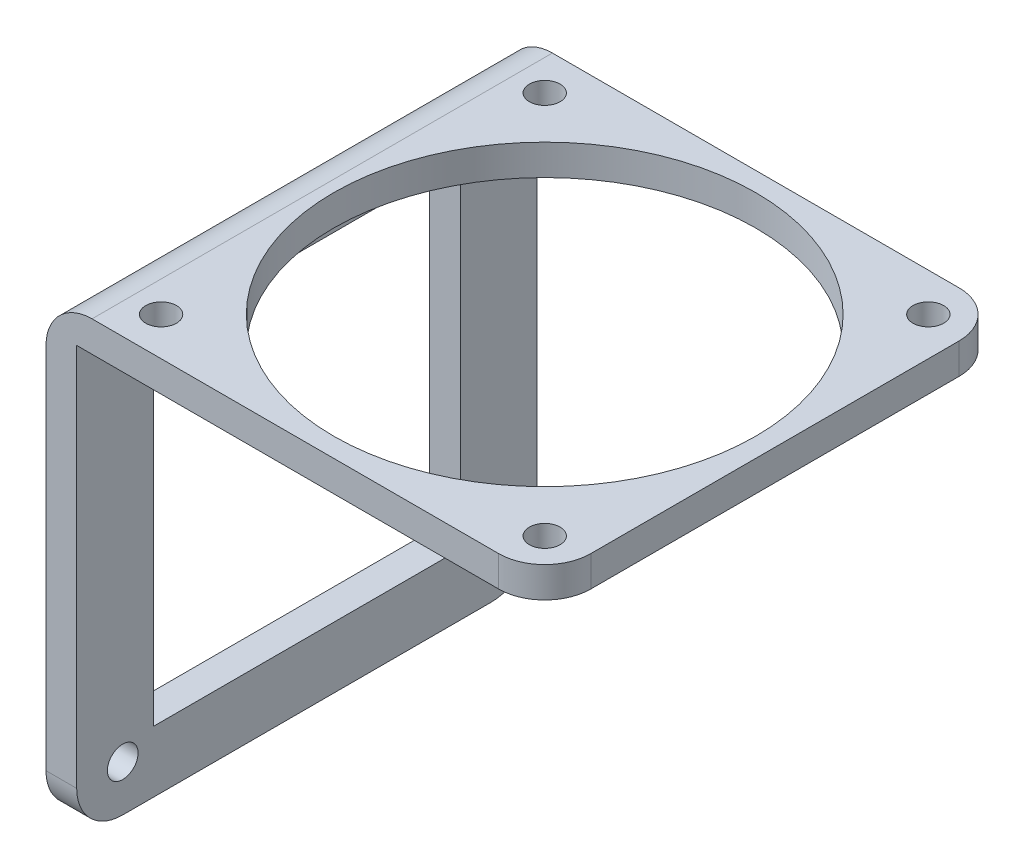
from build123d import *

# Parameters (mm, degrees)
RESSALTO_EXTRUS_O1_DEPTH = 60
ESBO_O2_W                = 40
ESBO_O2_H                = 44
CORTE_EXTRUS_O1_DEPTH    = 66
CORTE_EXTRUS_O3_REACH    = 62
ESBO_O4_R                = 2
ESBO_O5_R                = 27.5
CORTE_EXTRUS_O4_DEPTH    = 5
ESBO_O6_R                = 2
CORTE_EXTRUS_O5_DEPTH    = 10
FILETE2_R                = 6


with BuildPart() as part:
    # Esboço1 → Ressalto-extrusão1 (new body)
    with BuildSketch(Plane.XY):
        Polygon((0, 0), (4, 0), (4, 56), (65, 56), (65, 60), (0, 60), align=None)
    extrude(amount=RESSALTO_EXTRUS_O1_DEPTH)

    # Esboço2 → Corte-extrusão1 (cut, through all)
    with BuildSketch(Plane.ZY):
        with Locations((30, 30)):
            Rectangle(ESBO_O2_W, ESBO_O2_H)
    extrude(amount=-CORTE_EXTRUS_O1_DEPTH, mode=Mode.SUBTRACT)

    # Esboço4 → Corte-extrusão3 (cut, up to next)
    with BuildSketch(Plane.ZX.offset(60), mode=Mode.PRIVATE) as corte_extrus_o3_sk1:
        with Locations((5, 60)):
            Circle(ESBO_O4_R)
    corte_extrus_o3_tool1 = extrude(corte_extrus_o3_sk1.sketch, amount=-CORTE_EXTRUS_O3_REACH, mode=Mode.PRIVATE) & part.part
    add(corte_extrus_o3_tool1.solids().sort_by_distance((60, 60, 5))[0], mode=Mode.SUBTRACT)
    # Esboço4 → Corte-extrusão3 (cut, up to next)
    with BuildSketch(Plane.ZX.offset(60), mode=Mode.PRIVATE) as corte_extrus_o3_sk2:
        with Locations((55, 60)):
            Circle(ESBO_O4_R)
    corte_extrus_o3_tool2 = extrude(corte_extrus_o3_sk2.sketch, amount=-CORTE_EXTRUS_O3_REACH, mode=Mode.PRIVATE) & part.part
    add(corte_extrus_o3_tool2.solids().sort_by_distance((60, 60, 55))[0], mode=Mode.SUBTRACT)
    # Esboço4 → Corte-extrusão3 (cut, up to next)
    with BuildSketch(Plane.ZX.offset(60), mode=Mode.PRIVATE) as corte_extrus_o3_sk3:
        with Locations((5, 10)):
            Circle(ESBO_O4_R)
    corte_extrus_o3_tool3 = extrude(corte_extrus_o3_sk3.sketch, amount=-CORTE_EXTRUS_O3_REACH, mode=Mode.PRIVATE) & part.part
    add(corte_extrus_o3_tool3.solids().sort_by_distance((10, 60, 5))[0], mode=Mode.SUBTRACT)
    # Esboço4 → Corte-extrusão3 (cut, up to next)
    with BuildSketch(Plane.ZX.offset(60), mode=Mode.PRIVATE) as corte_extrus_o3_sk4:
        with Locations((55, 10)):
            Circle(ESBO_O4_R)
    corte_extrus_o3_tool4 = extrude(corte_extrus_o3_sk4.sketch, amount=-CORTE_EXTRUS_O3_REACH, mode=Mode.PRIVATE) & part.part
    add(corte_extrus_o3_tool4.solids().sort_by_distance((10, 60, 55))[0], mode=Mode.SUBTRACT)

    # Esboço5 → Corte-extrusão4 (cut, through all)
    with BuildSketch(Plane(origin=(0, 56, 0), x_dir=(0, 0, -1), z_dir=(0, -1, 0))):
        with Locations((-30, 35)):
            Circle(ESBO_O5_R)
    extrude(amount=-CORTE_EXTRUS_O4_DEPTH, mode=Mode.SUBTRACT)

    # Esboço6 → Corte-extrusão5 (cut)
    with BuildSketch(Plane.ZY):
        with Locations((6, 6)):
            Circle(ESBO_O6_R)
        with Locations((54, 6)):
            Circle(ESBO_O6_R)
    extrude(amount=-CORTE_EXTRUS_O5_DEPTH, mode=Mode.SUBTRACT)

    # Filete2
    filete2_edges = [part.edges().sort_by_distance(p)[0] for p in [
        (0, 60, 30),
        (65, 58, 60),
        (65, 58, 0),
        (2, 0, 60),
        (2, 0, 0),
    ]]
    fillet(filete2_edges, radius=FILETE2_R)


solid = part.part
